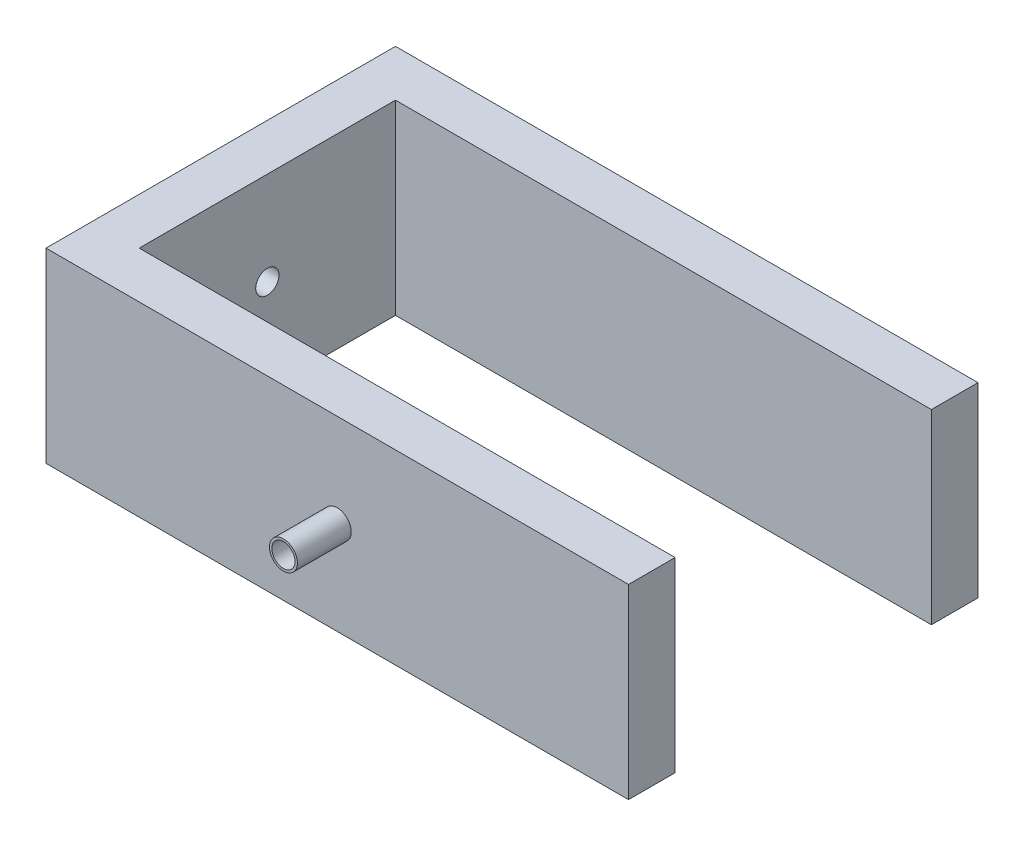
from build123d import *

# Parameters (mm, degrees)
SKETCH5_W            = 75
SKETCH5_H            = 40
SKETCH5_R            = 2.5
BOSS_EXTRUDE6_DEPTH  = 10
SKETCH6_W            = 125
SKETCH6_H            = 40
BOSS_EXTRUDE7_DEPTH  = 10
SKETCH7_W            = 125
SKETCH7_H            = 40
BOSS_EXTRUDE8_DEPTH  = 10
SKETCH8_R            = 2.5
BOSS_EXTRUDE9_DEPTH  = 11.55
SKETCH10_R           = 3
SKETCH10_R_2         = 2.5
BOSS_EXTRUDE10_DEPTH = 11.55


with BuildPart() as part:
    # Sketch5 → Boss-Extrude6 (new body)
    with BuildSketch(Plane(origin=(0, 0, 0), x_dir=(0, 0, -1), z_dir=(1, 0, 0))):
        Rectangle(SKETCH5_W, SKETCH5_H)
        Circle(SKETCH5_R, mode=Mode.SUBTRACT)
    extrude(amount=BOSS_EXTRUDE6_DEPTH)

    # Sketch6 → Boss-Extrude7 (add)
    with BuildSketch(Plane(origin=(0, 0, -37.5), x_dir=(-1, 0, 0), z_dir=(0, 0, -1))):
        with Locations((-62.5, 0)):
            Rectangle(SKETCH6_W, SKETCH6_H)
    extrude(amount=-BOSS_EXTRUDE7_DEPTH)

    # Sketch7 → Boss-Extrude8 (add)
    with BuildSketch(Plane.XY.offset(37.5)):
        with Locations((62.5, 0)):
            Rectangle(SKETCH7_W, SKETCH7_H)
    extrude(amount=-BOSS_EXTRUDE8_DEPTH)

    # Sketch8 → Boss-Extrude9 (add)
    with BuildSketch(Plane(origin=(0, 0, -37.5), x_dir=(-1, 0, 0), z_dir=(0, 0, -1))):
        with Locations((-62.5, 0)):
            Circle(SKETCH8_R)
    extrude(amount=BOSS_EXTRUDE9_DEPTH)

    # Sketch10 → Boss-Extrude10 (add)
    with BuildSketch(Plane(origin=(0, 0, 37.5), x_dir=(-1, 0, 0), z_dir=(0, 0, -1))):
        with Locations((-62.5, 0)):
            Circle(SKETCH10_R)
        with Locations((-62.5, 0)):
            Circle(SKETCH10_R_2, mode=Mode.SUBTRACT)
    extrude(amount=-BOSS_EXTRUDE10_DEPTH)


solid = part.part
